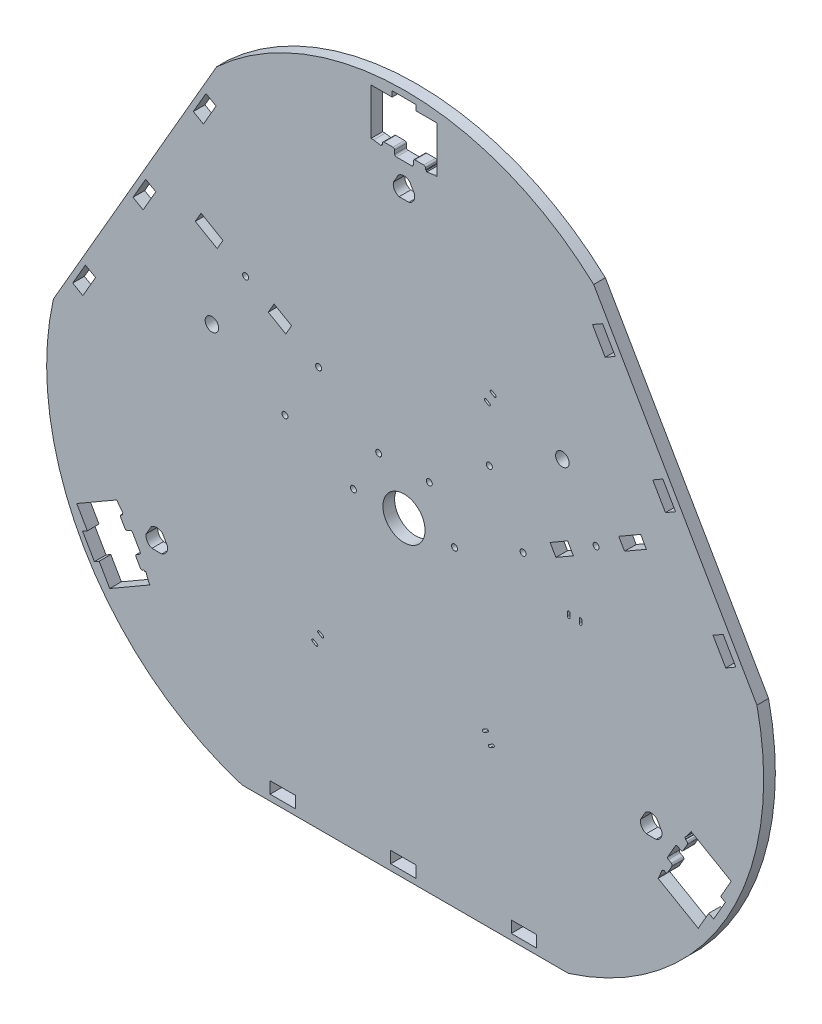
from build123d import *

# Parameters (mm, degrees)
SKETCH3_R           = 1.775
SKETCH3_R_2         = 4
SKETCH3_R_3         = 12.5
SKETCH3_W           = 15.06
SKETCH3_H           = 6.918
BOSS_EXTRUDE1_DEPTH = 6.92


with BuildPart() as part:
    # Sketch3 → Boss-Extrude1 (new body)
    with BuildSketch(Plane.XY):
        with BuildLine():
            Line((324.440003838, 361.341812593), (421.252189978, 193.658187407))
            ThreePointArc((421.252189978, 193.658187407), (403.156986041, 75), (309.443583349, 0))
            Line((309.443583349, 0), (115.819211068, 0))
            ThreePointArc((115.819211068, 0), (22.105808376, 75), (4.010604438, 193.658187407))
            Line((4.010604438, 193.658187407), (100.822790578, 361.341812593))
            ThreePointArc((100.822790578, 361.341812593), (212.631397208, 405), (324.440003838, 361.341812593))
        make_face()
        with Locations((181.931397208, 185)):
            Circle(SKETCH3_R, mode=Mode.SUBTRACT)
        with Locations((196.931397208, 210.980762114)):
            Circle(SKETCH3_R, mode=Mode.SUBTRACT)
        with Locations((118.008348754, 262.320508076)):
            Circle(SKETCH3_R, mode=Mode.SUBTRACT)
        with Locations((98.008348754, 227.679491925)):
            Circle(SKETCH3_R_2, mode=Mode.SUBTRACT)
        with Locations((161.309618943, 237.320508076)):
            Circle(SKETCH3_R, mode=Mode.SUBTRACT)
        with Locations((141.309618943, 202.679491925)):
            Circle(SKETCH3_R, mode=Mode.SUBTRACT)
        with Locations((211.931397208, 185)):
            Circle(SKETCH3_R_3, mode=Mode.SUBTRACT)
        with Locations((226.931397208, 210.980762114)):
            Circle(SKETCH3_R, mode=Mode.SUBTRACT)
        with Locations((241.931397208, 185)):
            Circle(SKETCH3_R, mode=Mode.SUBTRACT)
        with Locations((325.854445663, 227.679491925)):
            Circle(SKETCH3_R, mode=Mode.SUBTRACT)
        with Locations((305.854445663, 262.320508076)):
            Circle(SKETCH3_R_2, mode=Mode.SUBTRACT)
        with Locations((282.553175473, 202.679491925)):
            Circle(SKETCH3_R, mode=Mode.SUBTRACT)
        with Locations((262.553175473, 237.320508076)):
            Circle(SKETCH3_R, mode=Mode.SUBTRACT)
        with BuildLine():
            Line((43.84983908, 101.525798495), (46.47483908, 96.979165125))
            ThreePointArc((46.47483908, 96.979165125), (47.082045438, 96.513239299), (47.840864483, 96.613139721))
            Line((47.840864483, 96.613139721), (49.572915291, 97.613139721))
            ThreePointArc((49.572915291, 97.613139721), (50.331734336, 97.713040144), (50.938940695, 97.247114317))
            Line((50.938940695, 97.247114317), (55.438940695, 89.452885683))
            ThreePointArc((55.438940695, 89.452885683), (55.538841117, 88.694066638), (55.072915291, 88.086860279))
            Line((55.072915291, 88.086860279), (53.340864483, 87.086860279))
            ThreePointArc((53.340864483, 87.086860279), (52.874938657, 86.479653921), (52.97483908, 85.720834876))
            Line((52.97483908, 85.720834876), (55.59983908, 81.174201506))
            ThreePointArc((55.59983908, 81.174201506), (56.207045438, 80.708275679), (56.965864483, 80.808176102))
            Line((56.965864483, 80.808176102), (57.831889887, 81.308176102))
            Line((57.831889887, 81.308176102), (58.081889887, 80.8751634))
            Line((58.081889887, 80.8751634), (58.8210837, 80.99484216))
            Line((58.8210837, 80.99484216), (60.486889887, 76.709581208))
            Line((60.486889887, 76.709581208), (61.236889887, 75.410543102))
            Line((61.236889887, 75.410543102), (37.421191283, 61.660543102))
            Line((37.421191283, 61.660543102), (31.141191283, 72.537822174))
            Line((31.141191283, 72.537822174), (28.326608721, 70.912822174))
            Line((28.326608721, 70.912822174), (21.326608721, 83.037177827))
            Line((21.326608721, 83.037177827), (24.141191283, 84.662177827))
            Line((24.141191283, 84.662177827), (17.861191283, 95.539456898))
            Line((17.861191283, 95.539456898), (41.676889887, 109.289456898))
            Line((41.676889887, 109.289456898), (42.426889887, 107.990418793))
            Line((42.426889887, 107.990418793), (45.30513164, 104.40515784))
            Line((45.30513164, 104.40515784), (44.831889887, 103.8248366))
            Line((44.831889887, 103.8248366), (45.081889887, 103.391823898))
            Line((45.081889887, 103.391823898), (44.215864483, 102.891823898))
            ThreePointArc((44.215864483, 102.891823898), (43.749938657, 102.28461754), (43.84983908, 101.525798495))
        make_face(mode=Mode.SUBTRACT)
        with BuildLine():
            Line((378.557662777, 104.40515784), (379.03090453, 103.8248366))
            Line((379.03090453, 103.8248366), (378.78090453, 103.391823898))
            Line((378.78090453, 103.391823898), (379.646929933, 102.891823898))
            ThreePointArc((379.646929933, 102.891823898), (380.11285576, 102.28461754), (380.012955337, 101.525798495))
            Line((380.012955337, 101.525798495), (377.387955337, 96.979165125))
            ThreePointArc((377.387955337, 96.979165125), (376.780748978, 96.513239298), (376.021929933, 96.613139721))
            Line((376.021929933, 96.613139721), (374.289879126, 97.613139721))
            ThreePointArc((374.289879126, 97.613139721), (373.531060081, 97.713040143), (372.923853722, 97.247114317))
            Line((372.923853722, 97.247114317), (368.423853722, 89.452885683))
            ThreePointArc((368.423853722, 89.452885683), (368.3239533, 88.694066638), (368.789879126, 88.086860279))
            Line((368.789879126, 88.086860279), (370.521929933, 87.086860279))
            ThreePointArc((370.521929933, 87.086860279), (370.98785576, 86.479653921), (370.887955337, 85.720834876))
            Line((370.887955337, 85.720834876), (368.262955337, 81.174201506))
            ThreePointArc((368.262955337, 81.174201506), (367.655748978, 80.708275679), (366.896929933, 80.808176102))
            Line((366.896929933, 80.808176102), (366.03090453, 81.308176102))
            Line((366.03090453, 81.308176102), (365.78090453, 80.8751634))
            Line((365.78090453, 80.8751634), (365.041710717, 80.99484216))
            Line((365.041710717, 80.99484216), (363.37590453, 76.709581208))
            Line((363.37590453, 76.709581208), (362.62590453, 75.410543102))
            Line((362.62590453, 75.410543102), (386.441603134, 61.660543102))
            Line((386.441603134, 61.660543102), (392.721603134, 72.537822174))
            Line((392.721603134, 72.537822174), (395.536185696, 70.912822174))
            Line((395.536185696, 70.912822174), (402.536185696, 83.037177827))
            Line((402.536185696, 83.037177827), (399.721603134, 84.662177827))
            Line((399.721603134, 84.662177827), (406.001603134, 95.539456898))
            Line((406.001603134, 95.539456898), (382.18590453, 109.289456898))
            Line((382.18590453, 109.289456898), (381.43590453, 107.990418793))
            Line((381.43590453, 107.990418793), (378.557662777, 104.40515784))
        make_face(mode=Mode.SUBTRACT)
        with BuildLine():
            Line((224.681397208, 371.3), (224.681397208, 370.3))
            Line((224.681397208, 370.3), (225.181397208, 370.3))
            Line((225.181397208, 370.3), (225.447349268, 369.6))
            Line((225.447349268, 369.6), (229.991397208, 370.3))
            Line((229.991397208, 370.3), (231.491397208, 370.3))
            Line((231.491397208, 370.3), (231.491397208, 397.8))
            Line((231.491397208, 397.8), (218.931397208, 397.8))
            Line((218.931397208, 397.8), (218.931397208, 401.05))
            Line((218.931397208, 401.05), (204.931397208, 401.05))
            Line((204.931397208, 401.05), (204.931397208, 397.8))
            Line((204.931397208, 397.8), (192.371397208, 397.8))
            Line((192.371397208, 397.8), (192.371397208, 370.3))
            Line((192.371397208, 370.3), (193.871397208, 370.3))
            Line((193.871397208, 370.3), (198.415445149, 369.6))
            Line((198.415445149, 369.6), (198.681397208, 370.3))
            Line((198.681397208, 370.3), (199.181397208, 370.3))
            Line((199.181397208, 370.3), (199.181397208, 371.3))
            ThreePointArc((199.181397208, 371.3), (199.474290427, 372.007106781), (200.181397208, 372.3))
            Line((200.181397208, 372.3), (205.431397208, 372.3))
            ThreePointArc((205.431397208, 372.3), (206.13850399, 372.007106781), (206.431397208, 371.3))
            Line((206.431397208, 371.3), (206.431397208, 369.3))
            ThreePointArc((206.431397208, 369.3), (206.724290427, 368.592893219), (207.431397208, 368.3))
            Line((207.431397208, 368.3), (216.431397208, 368.3))
            ThreePointArc((216.431397208, 368.3), (217.13850399, 368.592893219), (217.431397208, 369.3))
            Line((217.431397208, 369.3), (217.431397208, 371.3))
            ThreePointArc((217.431397208, 371.3), (217.724290427, 372.007106781), (218.431397208, 372.3))
            Line((218.431397208, 372.3), (223.681397208, 372.3))
            ThreePointArc((223.681397208, 372.3), (224.38850399, 372.007106781), (224.681397208, 371.3))
        make_face(mode=Mode.SUBTRACT)
        Polygon((101.137904188, 268.100040941), (104.567904188, 274.040975211), (91.577523131, 281.540975211), (88.147523131, 275.600040941), align=None, mode=Mode.SUBTRACT)
        Polygon((23.003699887, 220.615193718), (15.473699887, 207.572851137), (21.46486363, 204.113851137), (28.99486363, 217.156193718), align=None, mode=Mode.SUBTRACT)
        Polygon((58.753792957, 282.53617129), (51.223792957, 269.49382871), (57.214956701, 266.03482871), (64.744956701, 279.07717129), align=None, mode=Mode.SUBTRACT)
        Polygon((94.503886027, 344.457148863), (86.973886027, 331.414806282), (92.965049771, 327.955806282), (100.495049771, 340.998148863), align=None, mode=Mode.SUBTRACT)
        Polygon((337.238908389, 330.8085885), (329.708908389, 343.850931081), (323.717744646, 340.391931081), (331.247744646, 327.3495885), align=None, mode=Mode.SUBTRACT)
        Polygon((372.989001459, 268.887610927), (365.459001459, 281.929953508), (359.467837716, 278.470953508), (366.997837716, 265.428610927), align=None, mode=Mode.SUBTRACT)
        Polygon((408.739094529, 206.966633354), (401.209094529, 220.008975935), (395.217930786, 216.549975935), (402.747930786, 203.507633354), align=None, mode=Mode.SUBTRACT)
        with Locations((283.081583349, 7.035217783)):
            Rectangle(SKETCH3_W, SKETCH3_H, mode=Mode.SUBTRACT)
        with Locations((211.581397209, 7.035217783)):
            Rectangle(SKETCH3_W, SKETCH3_H, mode=Mode.SUBTRACT)
        with Locations((140.081211068, 7.035217783)):
            Rectangle(SKETCH3_W, SKETCH3_H, mode=Mode.SUBTRACT)
        Polygon((141.841098166, 244.600040941), (145.271098166, 250.540975211), (134.87879332, 256.540975211), (131.44879332, 250.600040941), align=None, mode=Mode.SUBTRACT)
        with BuildLine():
            Line((218.19001863, 354.53487951), (215.285653046, 359.565388266))
            ThreePointArc((215.285653046, 359.565388266), (211.931394847, 360.875133888), (208.577136648, 359.565388266))
            Line((208.577136648, 359.565388266), (205.672771064, 354.53487951))
            ThreePointArc((205.672771064, 354.53487951), (206.215627182, 350.975133888), (209.027029263, 348.725133888))
            Line((209.027029263, 348.725133888), (214.835760431, 348.725133888))
            ThreePointArc((214.835760431, 348.725133888), (217.647162512, 350.975133888), (218.19001863, 354.53487951))
        make_face(mode=Mode.SUBTRACT)
        with BuildLine():
            Line((68.689090412, 105.652685389), (71.593455996, 100.622176634))
            ThreePointArc((71.593455996, 100.622176634), (71.050599878, 97.062431011), (68.239197797, 94.812431011))
            Line((68.239197797, 94.812431011), (62.430466629, 94.812431011))
            ThreePointArc((62.430466629, 94.812431011), (59.619064548, 97.062431011), (59.07620843, 100.622176634))
            Line((59.07620843, 100.622176634), (61.980574014, 105.652685389))
            ThreePointArc((61.980574014, 105.652685389), (65.334832213, 106.962431011), (68.689090412, 105.652685389))
        make_face(mode=Mode.SUBTRACT)
        with BuildLine():
            Line((355.623598981, 94.812435101), (361.432330149, 94.812435101))
            ThreePointArc((361.432330149, 94.812435101), (364.24373223, 97.062435101), (364.786588348, 100.622180723))
            Line((364.786588348, 100.622180723), (361.882222764, 105.652689479))
            ThreePointArc((361.882222764, 105.652689479), (358.527964565, 106.962435101), (355.173706366, 105.652689479))
            Line((355.173706366, 105.652689479), (352.269340782, 100.622180723))
            ThreePointArc((352.269340782, 100.622180723), (352.8121969, 97.062435101), (355.623598981, 94.812435101))
        make_face(mode=Mode.SUBTRACT)
        Polygon((298.591696251, 215.899959059), (302.021696251, 209.95902479), (312.414001096, 215.95902479), (308.984001096, 221.899959059), align=None, mode=Mode.SUBTRACT)
        Polygon((342.724890229, 233.45902479), (355.715271286, 240.95902479), (352.285271286, 246.89995906), (339.294890229, 239.399959059), align=None, mode=Mode.SUBTRACT)
        with BuildLine():
            Line((161.099485485, 100.643334497), (163.177946454, 99.443334497))
            ThreePointArc((163.177946454, 99.443334497), (164.202465506, 99.71785355), (163.927946454, 100.742372603))
            Line((163.927946454, 100.742372603), (161.849485485, 101.942372603))
            ThreePointArc((161.849485485, 101.942372603), (160.824966432, 101.66785355), (161.099485485, 100.643334497))
        make_face(mode=Mode.SUBTRACT)
        with BuildLine():
            Line((157.599485485, 94.581156671), (159.677946454, 93.381156671))
            ThreePointArc((159.677946454, 93.381156671), (160.702465506, 93.655675724), (160.427946454, 94.680194776))
            Line((160.427946454, 94.680194776), (158.349485485, 95.880194776))
            ThreePointArc((158.349485485, 95.880194776), (157.324966432, 95.605675724), (157.599485485, 94.581156671))
        make_face(mode=Mode.SUBTRACT)
        with BuildLine():
            Line((259.570456651, 98.799940373), (261.64891762, 99.999940373))
            ThreePointArc((261.64891762, 99.999940373), (261.923436672, 101.024459426), (260.89891762, 101.298978479))
            Line((260.89891762, 101.298978479), (258.820456651, 100.098978479))
            ThreePointArc((258.820456651, 100.098978479), (258.545937598, 99.074459426), (259.570456651, 98.799940373))
        make_face(mode=Mode.SUBTRACT)
        with BuildLine():
            Line((263.070456651, 92.737762547), (265.14891762, 93.937762547))
            ThreePointArc((265.14891762, 93.937762547), (265.423436672, 94.962281599), (264.39891762, 95.236800652))
            Line((264.39891762, 95.236800652), (262.320456651, 94.036800652))
            ThreePointArc((262.320456651, 94.036800652), (262.045937598, 93.012281599), (263.070456651, 92.737762547))
        make_face(mode=Mode.SUBTRACT)
        with BuildLine():
            Line((310.402368374, 183.156605876), (310.402368374, 185.556605876))
            ThreePointArc((310.402368374, 185.556605876), (309.652368374, 186.306605876), (308.902368374, 185.556605876))
            Line((308.902368374, 185.556605876), (308.902368374, 183.156605876))
            ThreePointArc((308.902368374, 183.156605876), (309.652368374, 182.406605876), (310.402368374, 183.156605876))
        make_face(mode=Mode.SUBTRACT)
        with BuildLine():
            Line((317.402368374, 183.156605876), (317.402368374, 185.556605876))
            ThreePointArc((317.402368374, 185.556605876), (316.652368374, 186.306605876), (315.902368374, 185.556605876))
            Line((315.902368374, 185.556605876), (315.902368374, 183.156605876))
            ThreePointArc((315.902368374, 183.156605876), (316.652368374, 182.406605876), (317.402368374, 183.156605876))
        make_face(mode=Mode.SUBTRACT)
        with BuildLine():
            Line((262.763308932, 269.356665503), (260.684847963, 270.556665503))
            ThreePointArc((260.684847963, 270.556665503), (259.66032891, 270.28214645), (259.934847963, 269.257627397))
            Line((259.934847963, 269.257627397), (262.013308932, 268.057627397))
            ThreePointArc((262.013308932, 268.057627397), (263.037827985, 268.33214645), (262.763308932, 269.356665503))
        make_face(mode=Mode.SUBTRACT)
        with BuildLine():
            Line((266.263308932, 275.41884333), (264.184847963, 276.61884333))
            ThreePointArc((264.184847963, 276.61884333), (263.16032891, 276.344324277), (263.434847963, 275.319805224))
            Line((263.434847963, 275.319805224), (265.513308932, 274.119805224))
            ThreePointArc((265.513308932, 274.119805224), (266.537827985, 274.394324277), (266.263308932, 275.41884333))
        make_face(mode=Mode.SUBTRACT)
    extrude(amount=BOSS_EXTRUDE1_DEPTH)


solid = part.part
